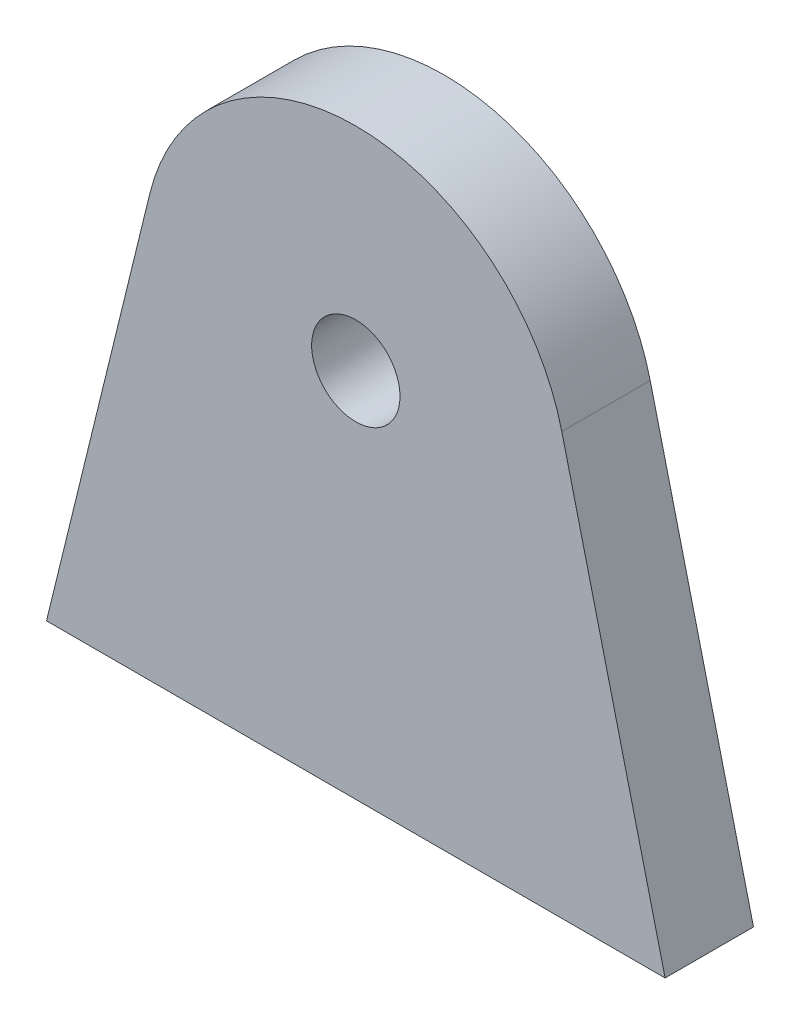
from build123d import *

# Parameters (mm, degrees)
SZKIC1_R                    = 2.5
DODANIE_WYCI_GNI_CIE1_DEPTH = 5


with BuildPart() as part:
    # Szkic1 → Dodanie-wyciągnięcie1 (new body)
    with BuildSketch(Plane.XY):
        with BuildLine():
            Line((17.5, 0), (-17.5, 0))
            Line((-17.5, 0), (-11.655281822, 23.855591995))
            ThreePointArc((-11.655281822, 23.855591995), (0, 33), (11.655281822, 23.855591995))
            Line((11.655281822, 23.855591995), (17.5, 0))
        make_face()
        with Locations((0, 21)):
            Circle(SZKIC1_R, mode=Mode.SUBTRACT)
    extrude(amount=DODANIE_WYCI_GNI_CIE1_DEPTH)


solid = part.part
